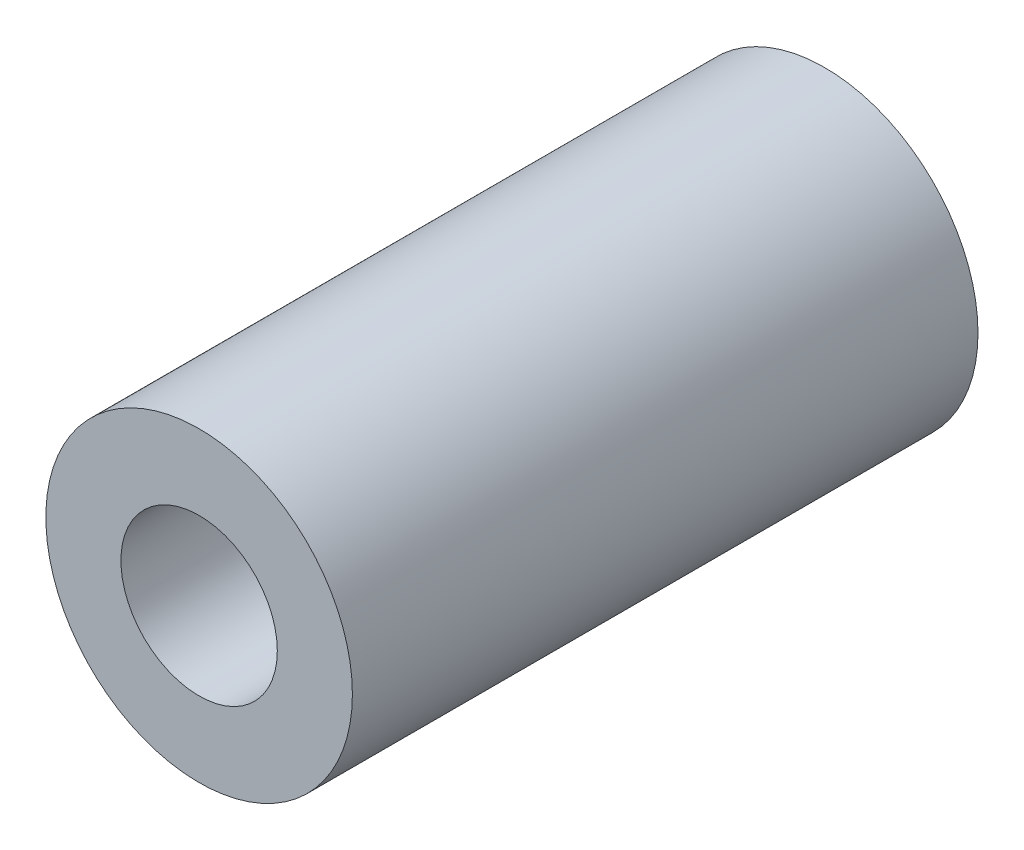
from build123d import *

# Parameters (mm, degrees)
SKETCH_1_R      = 2.45
SKETCH_1_R_2    = 1.25
EXTRUDE_1_DEPTH = 10


with BuildPart() as part:
    # ｽｹｯﾁ1 → ﾎﾞｽ - 押し出し1 (new body)
    with BuildSketch(Plane(origin=(0, 0, 0), x_dir=(0, 1, 0), z_dir=(0, 0, 1))):
        Circle(SKETCH_1_R)
        Circle(SKETCH_1_R_2, mode=Mode.SUBTRACT)
    extrude(amount=EXTRUDE_1_DEPTH)


solid = part.part
